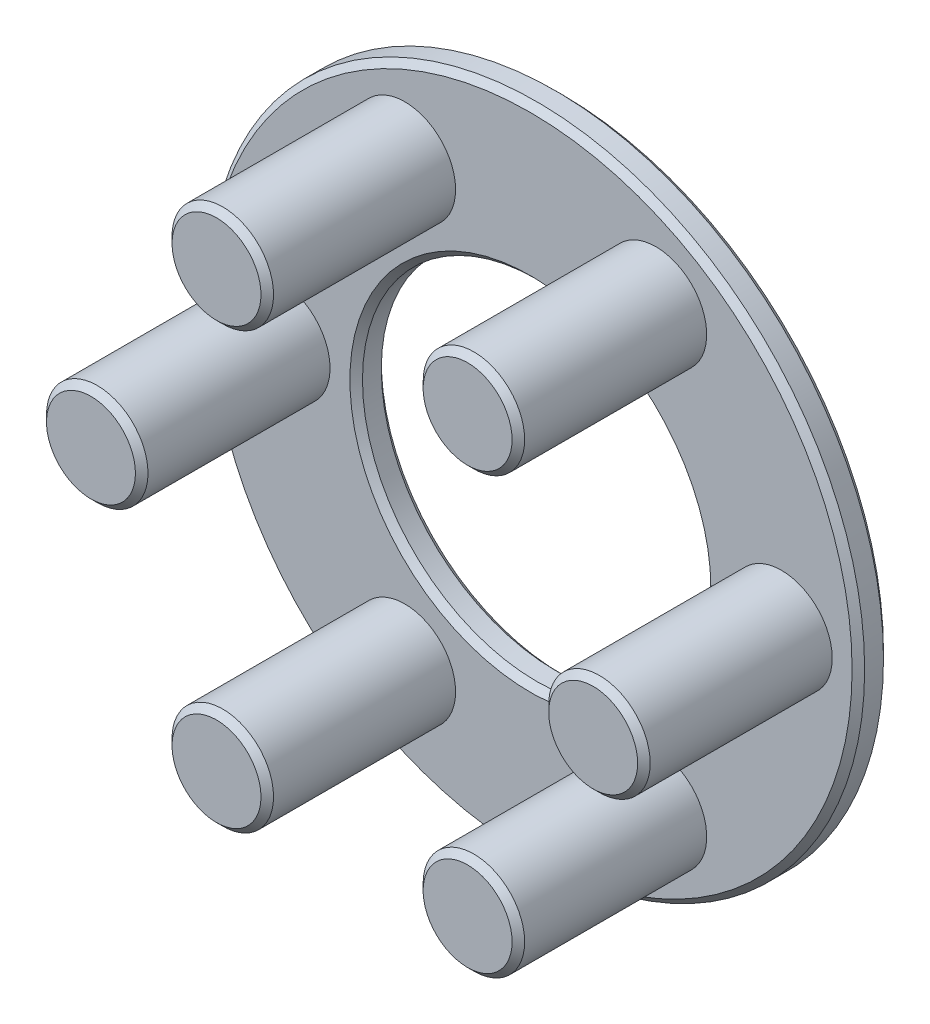
from build123d import *

# Parameters (mm, degrees)
SKETCH1_R           = 31.35
SKETCH1_R_2         = 16.65
BOSS_EXTRUDE1_DEPTH = 3
SKETCH2_R           = 4.85
BOSS_EXTRUDE2_DEPTH = 18
CIRPATTERN1_COUNT   = 6
CHAMFER1_SIZE       = 0.6


with BuildPart() as part:
    # Sketch1 → Boss-Extrude1 (new body)
    with BuildSketch(Plane.XY):
        Circle(SKETCH1_R)
        Circle(SKETCH1_R_2, mode=Mode.SUBTRACT)
    extrude(amount=-BOSS_EXTRUDE1_DEPTH)

    # Sketch2 → Boss-Extrude2 (add)
    with BuildSketch(Plane.XY):
        with Locations((24, 0)):
            Circle(SKETCH2_R)
    boss_extrude2 = extrude(amount=BOSS_EXTRUDE2_DEPTH)

    # CirPattern1: Boss-Extrude2 ×6 about axis
    cirpattern1_axis = Axis((0, 0, 0), (0, 0, 1))
    for i in range(1, CIRPATTERN1_COUNT):
        add(boss_extrude2.rotate(cirpattern1_axis, i * 360 / CIRPATTERN1_COUNT))

    # Chamfer1
    chamfer1_edges = [part.edges().sort_by_distance(p)[0] for p in [
        (19.15, 0, 18),
        (9.575, -16.584386482, 18),
        (-9.575, -16.584386482, 18),
        (-31.35, 0, 0),
        (-19.15, 0, 18),
        (-9.575, 16.584386482, 18),
        (9.575, 16.584386482, 18),
        (-31.35, 0, -3),
        (-16.65, 0, -3),
        (-16.65, 0, 0),
    ]]
    chamfer(chamfer1_edges, length=CHAMFER1_SIZE)


solid = part.part
